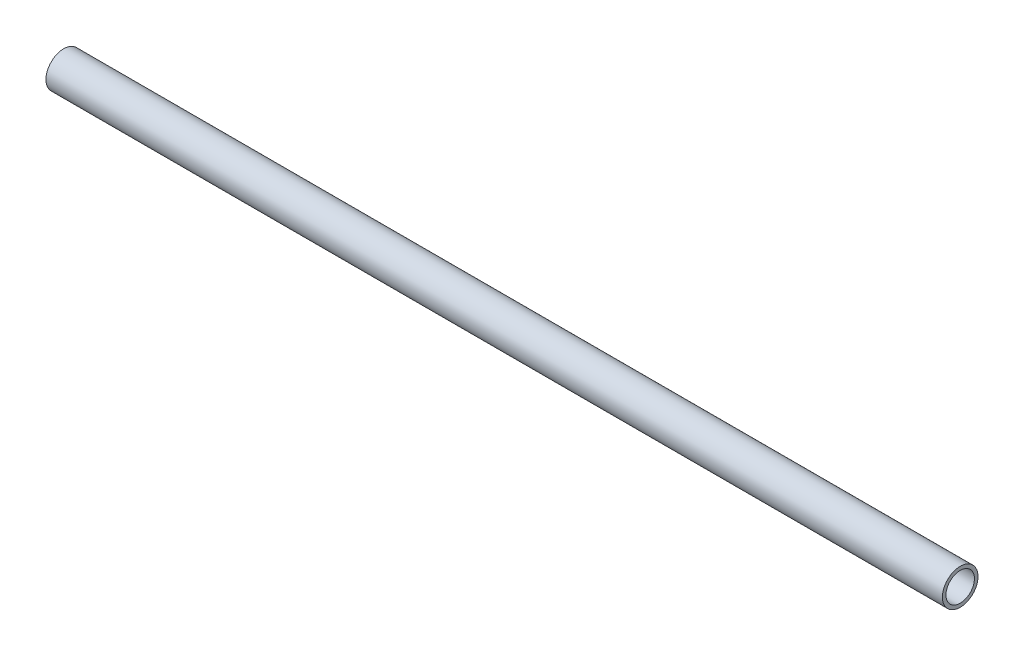
from build123d import *

# Parameters (mm, degrees)
SKETCH_1_R      = 5
SKETCH_1_R_2    = 4
EXTRUDE_1_DEPTH = 126


with BuildPart() as part:
    # 草圖1 → 填料-伸長1 (new body, symmetric)
    with BuildSketch(Plane(origin=(0, 0, 0), x_dir=(0, 0, -1), z_dir=(1, 0, 0))):
        Circle(SKETCH_1_R)
        Circle(SKETCH_1_R_2, mode=Mode.SUBTRACT)
    extrude(amount=EXTRUDE_1_DEPTH, both=True)


solid = part.part
